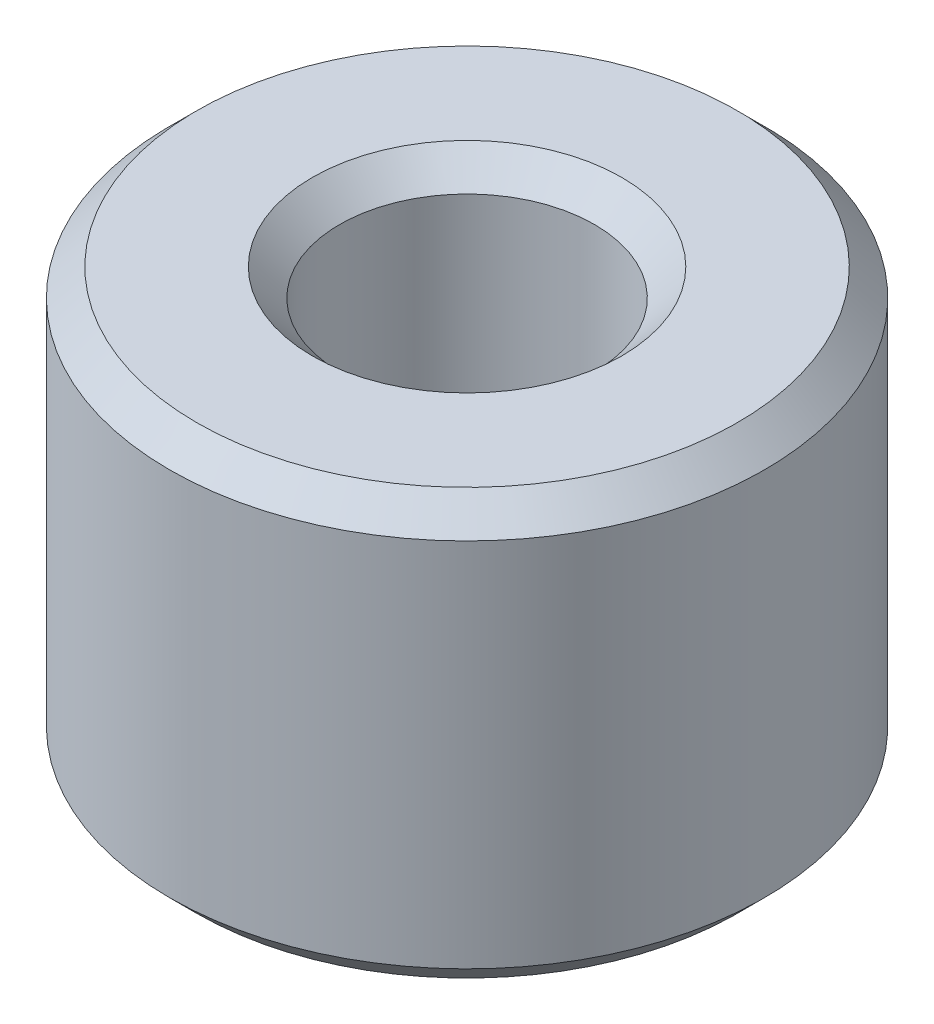
from build123d import *

# Parameters (mm, degrees)
SKETCH1_R           = 5.55625
SKETCH1_R_2         = 2.38125
BOSS_EXTRUDE1_DEPTH = 7.9375
CHAMFER1_SIZE       = 0.508


with BuildPart() as part:
    # Sketch1 → Boss-Extrude1 (new body)
    with BuildSketch(Plane(origin=(0, 0, 0), x_dir=(1, 0, 0), z_dir=(0, 1, 0))):
        Circle(SKETCH1_R)
        Circle(SKETCH1_R_2, mode=Mode.SUBTRACT)
    extrude(amount=BOSS_EXTRUDE1_DEPTH)

    # Chamfer1
    chamfer1_edges = [part.edges().sort_by_distance(p)[0] for p in [
        (-5.55625, 0, 0),
        (-5.55625, 7.9375, 0),
        (-2.38125, 0, 0),
        (-2.38125, 7.9375, 0),
    ]]
    chamfer(chamfer1_edges, length=CHAMFER1_SIZE)


solid = part.part
